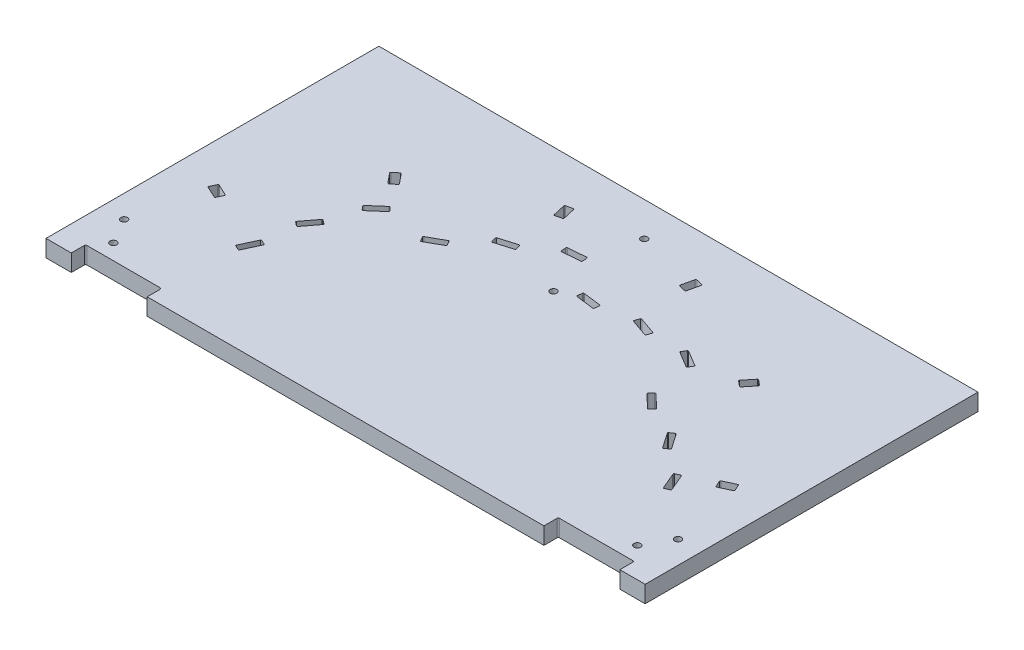
from build123d import *

# Parameters (mm, degrees)
SKETCH1_W                = 450
SKETCH1_H                = 250
BOSS_EXTRUDE1_DEPTH      = 12.7
CUT_EXTRUDE1_DEPTH       = 13.7
CIRPATTERN1_COUNT        = 4
CIRPATTERN1_ANGLE        = 108.1575
CUT_EXTRUDE2_DEPTH       = 13.7
CIRPATTERN2_COUNT        = 6
CIRPATTERN2_ANGLE        = 130
F_5_0_5_DIAMETER_HOLE1_D = 5
CUT_EXTRUDE3_DEPTH       = 13.7


with BuildPart() as part:
    # Sketch1 → Boss-Extrude1 (new body)
    with BuildSketch(Plane(origin=(0, 0, 0), x_dir=(1, 0, 0), z_dir=(0, 1, 0))):
        with Locations((-100.217846236, 140)):
            Rectangle(SKETCH1_W, SKETCH1_H)
    extrude(amount=BOSS_EXTRUDE1_DEPTH)

    # Sketch2 → Cut-Extrude1 (cut, through all)
    with BuildSketch(Plane.XZ):
        with BuildLine():
            Line((38.739246668, -124.339408402), (46.393470581, -113.21902818))
            ThreePointArc((46.393470581, -113.21902818), (46.489260345, -112.769909667), (46.23941919, -112.38460133))
            Line((46.23941919, -112.38460133), (43.287164174, -110.352546625))
            ThreePointArc((43.287164174, -110.352546625), (42.838045661, -110.256756862), (42.452737323, -110.506598017))
            Line((42.452737323, -110.506598017), (34.79851341, -121.626978239))
            ThreePointArc((34.79851341, -121.626978239), (34.702723647, -122.076096752), (34.952564801, -122.461405089))
            Line((34.952564801, -122.461405089), (37.904819817, -124.493459793))
            ThreePointArc((37.904819817, -124.493459793), (38.35393833, -124.589249557), (38.739246668, -124.339408402))
        make_face()
        with BuildLine():
            Line((67.922997839, -99.093027988), (73.190993439, -86.6632966))
            ThreePointArc((73.190993439, -86.6632966), (73.194746834, -86.204091821), (72.872694071, -85.876730957))
            Line((72.872694071, -85.876730957), (69.572830568, -84.47817568))
            ThreePointArc((69.572830568, -84.47817568), (69.113625788, -84.474422286), (68.786264924, -84.796475049))
            Line((68.786264924, -84.796475049), (63.518269324, -97.226206436))
            ThreePointArc((63.518269324, -97.226206436), (63.514515929, -97.685411215), (63.836568692, -98.01277208))
            Line((63.836568692, -98.01277208), (67.136432195, -99.411327356))
            ThreePointArc((67.136432195, -99.411327356), (67.595636975, -99.41508075), (67.922997839, -99.093027988))
        make_face()
        with BuildLine():
            Line((14.721360952, -132.90787696), (12.276275504, -130.287454637))
            ThreePointArc((12.276275504, -130.287454637), (11.858344628, -130.097147252), (11.42825523, -130.258101366))
            Line((11.42825523, -130.258101366), (1.557802842, -139.468105149))
            ThreePointArc((1.557802842, -139.468105149), (1.367495457, -139.886036024), (1.528449571, -140.316125423))
            Line((1.528449571, -140.316125423), (3.97353502, -142.936547745))
            ThreePointArc((3.97353502, -142.936547745), (4.391465895, -143.12685513), (4.821555294, -142.965901017))
            Line((4.821555294, -142.965901017), (14.692007681, -133.755897234))
            ThreePointArc((14.692007681, -133.755897234), (14.882315066, -133.337966359), (14.721360952, -132.90787696))
        make_face()
    cut_extrude1 = extrude(amount=-CUT_EXTRUDE1_DEPTH, mode=Mode.SUBTRACT)

    # CirPattern1: Cut-Extrude1 ×4 about axis
    cirpattern1_axis = Axis((-100.217846236, 0, -20.5), (0, 1, 0))
    for i in range(1, CIRPATTERN1_COUNT):
        add(cut_extrude1.rotate(cirpattern1_axis, i * CIRPATTERN1_ANGLE / (CIRPATTERN1_COUNT - 1)), mode=Mode.SUBTRACT)

    # Sketch3 → Cut-Extrude2 (cut, through all)
    with BuildSketch(Plane.XZ):
        with BuildLine():
            Line((95.31554912, -114.437164477), (97.428640428, -109.905625541))
            ThreePointArc((97.428640428, -109.905625541), (97.448671329, -109.446842498), (97.138426713, -109.108269912))
            Line((97.138426713, -109.108269912), (88.528502736, -105.093396426))
            ThreePointArc((88.528502736, -105.093396426), (88.069719693, -105.073365525), (87.731147107, -105.383610141))
            Line((87.731147107, -105.383610141), (85.618055798, -109.915149076))
            ThreePointArc((85.618055798, -109.915149076), (85.598024898, -110.373932119), (85.908269513, -110.712504705))
            Line((85.908269513, -110.712504705), (94.51819349, -114.727378192))
            ThreePointArc((94.51819349, -114.727378192), (94.976976533, -114.747409092), (95.31554912, -114.437164477))
        make_face()
    cut_extrude2 = extrude(amount=-CUT_EXTRUDE2_DEPTH, mode=Mode.SUBTRACT)

    # CirPattern2: Cut-Extrude2 ×6 about axis
    cirpattern2_axis = Axis((-100.217846236, 0, -20.5), (0, 1, 0))
    for i in range(1, CIRPATTERN2_COUNT):
        add(cut_extrude2.rotate(cirpattern2_axis, i * CIRPATTERN2_ANGLE / (CIRPATTERN2_COUNT - 1)), mode=Mode.SUBTRACT)

    # 5.0 _5_ Diameter Hole1 (through all)
    with Locations(Plane.XZ):
        with Locations((107.782153764, -56.669607055), (96.532153764, -37.366246808), (62.282153764, -19.9), (92.282153764, -19.9), (-262.717846236, -19.9), (-292.717846236, -19.9), (-296.967846236, -37.366246808), (-308.217846236, -56.669607055), (-100.217846236, -239.34531583), (-100.217846236, -171.14443084)):
            Hole(F_5_0_5_DIAMETER_HOLE1_D / 2)

    # Sketch7 → Cut-Extrude3 (cut, through all)
    with BuildSketch(Plane.XZ):
        with BuildLine():
            Line((105.782153764, -15), (105.782153764, -24.75))
            ThreePointArc((105.782153764, -24.75), (105.489260546, -25.457106781), (104.782153764, -25.75))
            Line((104.782153764, -25.75), (49.782153764, -25.75))
            ThreePointArc((49.782153764, -25.75), (49.075046983, -25.457106781), (48.782153764, -24.75))
            Line((48.782153764, -24.75), (48.782153764, -15))
            Line((48.782153764, -15), (105.782153764, -15))
        make_face()
    cut_extrude3 = extrude(amount=-CUT_EXTRUDE3_DEPTH, mode=Mode.SUBTRACT)

    # Mirror1: Cut-Extrude3 across plane
    add(cut_extrude3.mirror(Plane(origin=(-100.217846236, 0, 0), x_dir=(0, 0, 1), z_dir=(1, 0, 0))), mode=Mode.SUBTRACT)


solid = part.part
